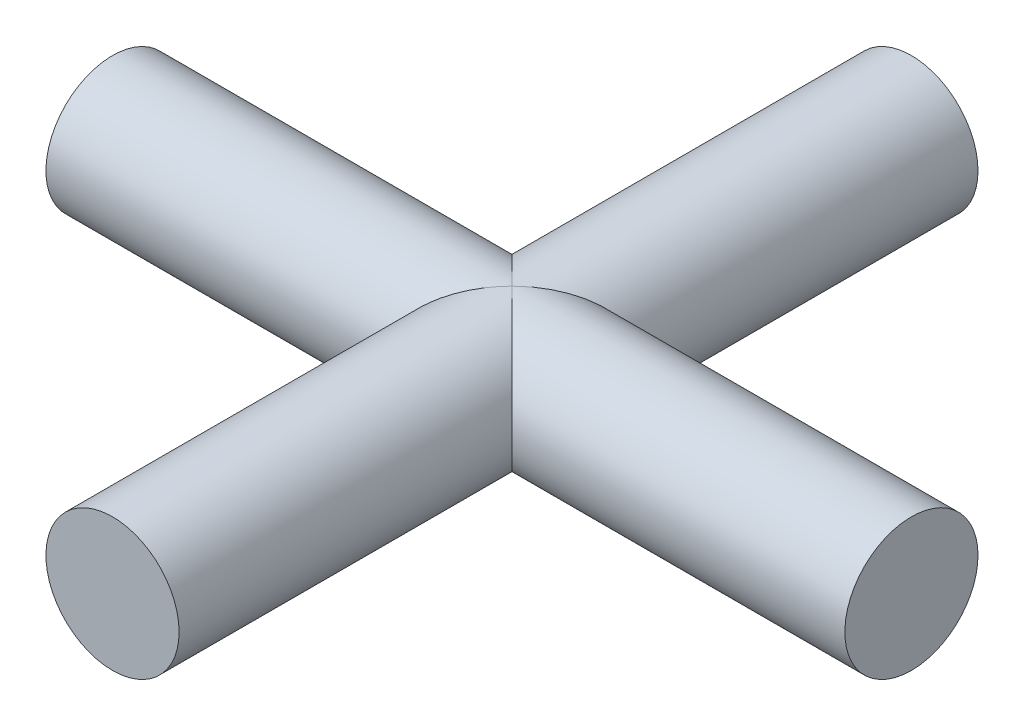
from build123d import *

# Parameters (mm, degrees)
ESQUISSE1_R        = 2.5
BOSS_EXTRU_1_DEPTH = 15
ESQUISSE3_R        = 2.5
BOSS_EXTRU_2_DEPTH = 15


with BuildPart() as part:
    # Esquisse1 → Boss.-Extru.1 (new body, symmetric)
    with BuildSketch(Plane.XY):
        Circle(ESQUISSE1_R)
    extrude(amount=BOSS_EXTRU_1_DEPTH, both=True)

    # Esquisse3 → Boss.-Extru.2 (add, symmetric)
    with BuildSketch(Plane(origin=(0, 0, 0), x_dir=(0, 0, -1), z_dir=(1, 0, 0))):
        with Locations(Location((0, 0, 0), (0, 0, 270))):  # turned: the seam where the file's is
            Circle(ESQUISSE3_R)
    extrude(amount=BOSS_EXTRU_2_DEPTH, both=True)


solid = part.part
